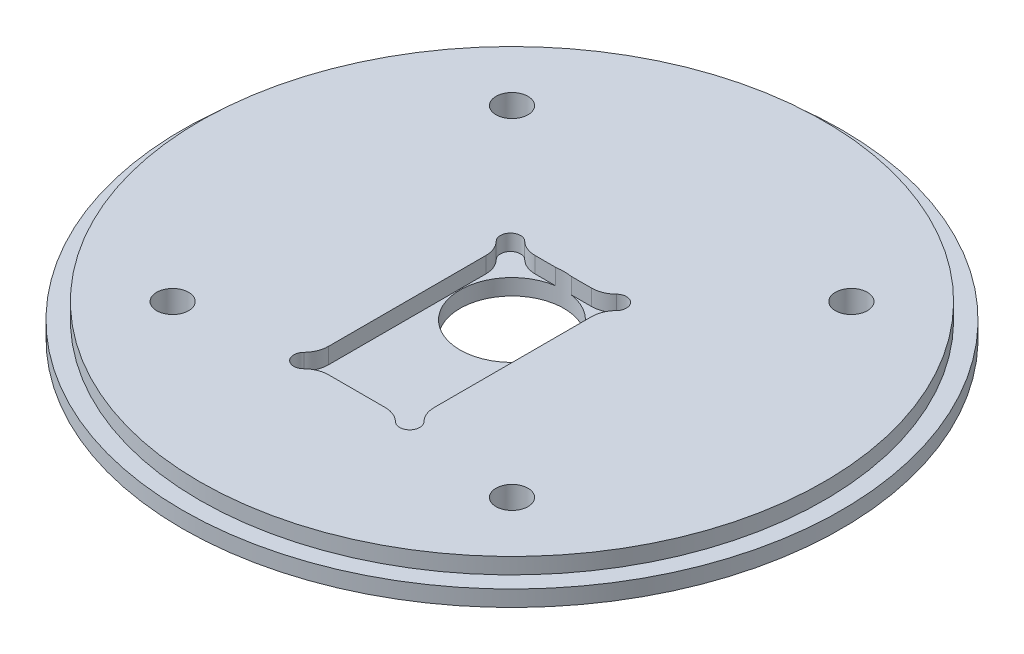
from build123d import *

# Parameters (mm, degrees)
SKETCH2_R                       = 65.405
BOSS_EXTRUDE1_DEPTH             = 6.35
SKETCH4_R                       = 65.405
SKETCH4_R_2                     = 61.976
CUT_EXTRUDE1_DEPTH              = 3.175
F_1_4_0_25_DIAMETER_HOLE1_D     = 6.35
F_13_16_0_8125_DIAMETER_HOLE1_D = 20.6375
CUT_EXTRUDE3_DEPTH              = 3.175
SKETCH9_R                       = 6.0325
CUT_EXTRUDE2_DEPTH              = 1.5875


with BuildPart() as part:
    # Sketch2 → Boss-Extrude1 (new body)
    with BuildSketch(Plane(origin=(0, 0, 0), x_dir=(1, 0, 0), z_dir=(0, 1, 0))):
        Circle(SKETCH2_R)
    extrude(amount=BOSS_EXTRUDE1_DEPTH)

    # Sketch4 → Cut-Extrude1 (cut)
    with BuildSketch(Plane(origin=(0, 6.35, 0), x_dir=(1, 0, 0), z_dir=(0, 1, 0))):
        Circle(SKETCH4_R)
        Circle(SKETCH4_R_2, mode=Mode.SUBTRACT)
    extrude(amount=-CUT_EXTRUDE1_DEPTH, mode=Mode.SUBTRACT)

    # 1/4 (0.25) Diameter Hole1 (through all)
    with Locations(Plane(origin=(0, 6.35, 0), x_dir=(1, 0, 0), z_dir=(0, 1, 0))):
        with Locations((-33.675960454, 33.675960454), (-33.675960454, -33.675960454), (33.675960454, 33.675960454), (33.675960454, -33.675960454)):
            Hole(F_1_4_0_25_DIAMETER_HOLE1_D / 2)

    # 13/16 (0.8125) Diameter Hole1 (through all)
    with Locations(Plane(origin=(0, 6.35, 0), x_dir=(1, 0, 0), z_dir=(0, 1, 0))):
        with Locations((0, 0)):
            Hole(F_13_16_0_8125_DIAMETER_HOLE1_D / 2)

    # Sketch11 → Cut-Extrude3 (cut)
    with BuildSketch(Plane(origin=(0, 6.35, 0), x_dir=(1, 0, 0), z_dir=(0, 1, 0))):
        with BuildLine():
            Line((-5.601020514, 10.2), (5.601020514, 10.2))
            ThreePointArc((5.601020514, 10.2), (7.490842879, 10.570899501), (9.100291576, 11.628571429))
            ThreePointArc((9.100291576, 11.628571429), (11.914213562, 11.614213562), (11.928571429, 8.800291576))
            ThreePointArc((11.928571429, 8.800291576), (10.870899501, 7.190842879), (10.5, 5.301020514))
            Line((10.5, 5.301020514), (10.5, -25.901020514))
            ThreePointArc((10.5, -25.901020514), (10.870899501, -27.790842879), (11.928571429, -29.400291576))
            ThreePointArc((11.928571429, -29.400291576), (11.914213562, -32.214213562), (9.100291576, -32.228571429))
            ThreePointArc((9.100291576, -32.228571429), (7.490842879, -31.170899501), (5.601020514, -30.8))
            Line((5.601020514, -30.8), (-5.601020514, -30.8))
            ThreePointArc((-5.601020514, -30.8), (-7.490842879, -31.170899501), (-9.100291576, -32.228571429))
            ThreePointArc((-9.100291576, -32.228571429), (-11.914213562, -32.214213562), (-11.928571429, -29.400291576))
            ThreePointArc((-11.928571429, -29.400291576), (-10.870899501, -27.790842879), (-10.5, -25.901020514))
            Line((-10.5, -25.901020514), (-10.5, 5.301020514))
            ThreePointArc((-10.5, 5.301020514), (-10.870899501, 7.190842879), (-11.928571429, 8.800291576))
            ThreePointArc((-11.928571429, 8.800291576), (-11.914213562, 11.614213562), (-9.100291576, 11.628571429))
            ThreePointArc((-9.100291576, 11.628571429), (-7.490842879, 10.570899501), (-5.601020514, 10.2))
        make_face()
    extrude(amount=-CUT_EXTRUDE3_DEPTH, mode=Mode.SUBTRACT)

    # Sketch9 → Cut-Extrude2 (cut)
    with BuildSketch(Plane.XZ):
        with Locations((-33.675960454, 33.675960454)):
            Circle(SKETCH9_R)
        with Locations((33.675960454, 33.675960454)):
            Circle(SKETCH9_R)
        with Locations((33.675960454, -33.675960454)):
            Circle(SKETCH9_R)
        with Locations((-33.675960454, -33.675960454)):
            Circle(SKETCH9_R)
    extrude(amount=-CUT_EXTRUDE2_DEPTH, mode=Mode.SUBTRACT)


solid = part.part
